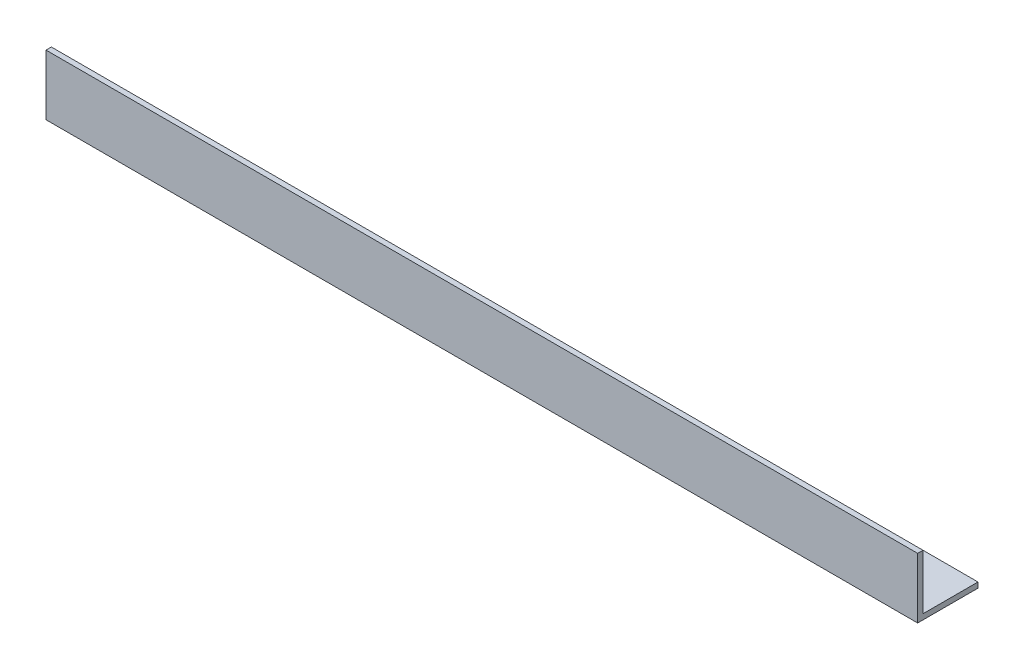
from build123d import *

# Parameters (mm, degrees)
EXTRUDE_1_DEPTH = 650


with BuildPart() as part:
    # Эскиз1 → Вытянуть-Тонкостенный1 (new body)
    with BuildSketch(Plane(origin=(0, 0, 0), x_dir=(0, 0, -1), z_dir=(1, 0, 0))):
        Polygon((0, 45), (0, 0), (45, 0), (45, 4), (4, 4), (4, 45), align=None)
    extrude(amount=EXTRUDE_1_DEPTH)


solid = part.part
